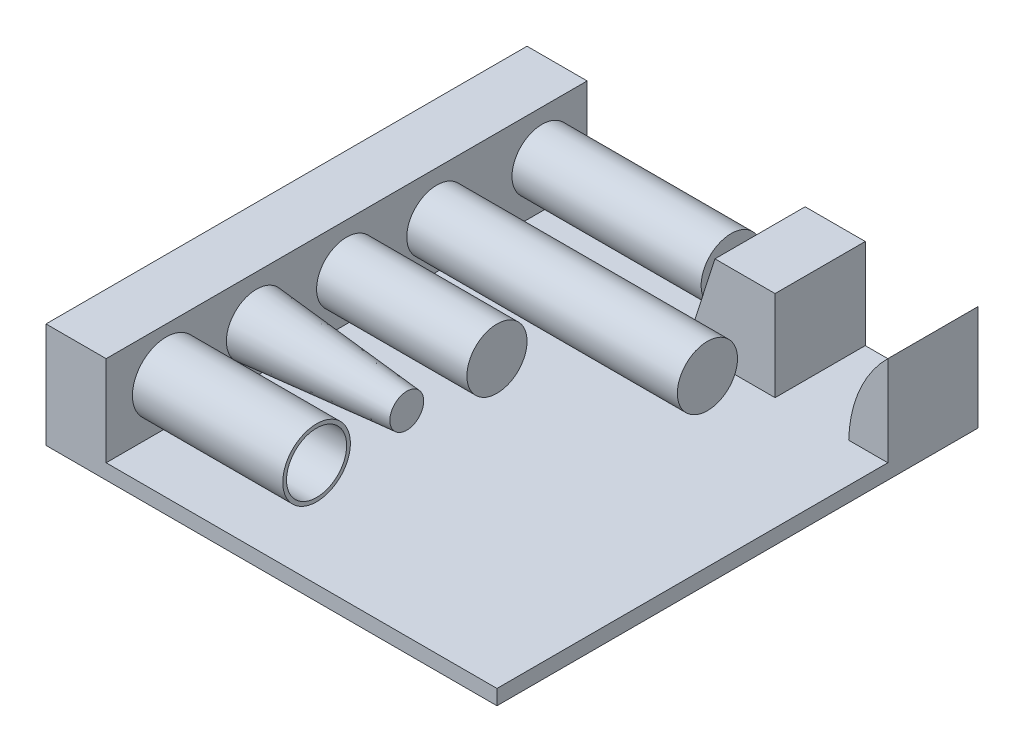
from build123d import *

# Parameters (mm, degrees)
BOSS_EXTRUDE1_DEPTH             = 640
BOSS_EXTRUDE2_DEPTH             = 120
ONE_SIDE_R                      = 40
BOSS_EXTRUDE3_DEPTH             = 251.6
BOTH_SIDES_R                    = 40
BOSS_EXTRUDE4_DEPTH             = 200
BOSS_EXTRUDE4_DIRECTION_2_REACH = 242
SOLID_2_R                       = 40
BOSS_EXTRUDE5_DEPTH             = 200
DRAFT_2_R                       = 40
BOSS_EXTRUDE6_DEPTH             = 200
BOSS_EXTRUDE6_TAPER             = 5
THICKEN_2_R                     = 45
THICKEN_2_R_2                   = 40
EXTRUDE_THIN1_DEPTH             = 200


with BuildPart() as part:
    # Sketch1 → Boss-Extrude1 (new body)
    with BuildSketch(Plane.XY):
        Polygon((-300, 0), (300, 0), (300, 20), (-220, 20), (-220, 140), (-300, 140), align=None)
    extrude(amount=BOSS_EXTRUDE1_DEPTH)

    # Sketch2 → Boss-Extrude2 (add)
    with BuildSketch(Plane.XY):
        with BuildLine():
            Line((300, 140), (300, 20))
            Line((300, 20), (247.956312481, 20))
            ThreePointArc((247.956312481, 20), (262.414199332, 85.015257999), (300, 140))
        make_face()
        Polygon((150, 140), (70, 140), (31.6, 20), (150, 20), align=None)
    extrude(amount=BOSS_EXTRUDE2_DEPTH)

    # One_Side → Boss-Extrude3 (add)
    with BuildSketch(Plane(origin=(-220, 0, 0), x_dir=(0, 0, -1), z_dir=(1, 0, 0))):
        with Locations((-60, 80)):
            Circle(ONE_SIDE_R)
    extrude(amount=BOSS_EXTRUDE3_DEPTH)

    # Both_Sides → Boss-Extrude4 (add)
    with BuildSketch(Plane(origin=(-60, 0, 0), x_dir=(0, 0, -1), z_dir=(1, 0, 0))):
        with Locations((-200, 80)):
            Circle(BOTH_SIDES_R)
    extrude(amount=BOSS_EXTRUDE4_DEPTH)

    # Both_Sides → Boss-Extrude4 direction 2 (add, up to next)
    with BuildSketch(Plane(origin=(-60, 0, 0), x_dir=(0, 0, -1), z_dir=(1, 0, 0)), mode=Mode.PRIVATE) as boss_extrude4_direction_2_sk1:
        with Locations((-200, 80)):
            Circle(BOTH_SIDES_R)
    boss_extrude4_direction_2_tool1 = extrude(boss_extrude4_direction_2_sk1.sketch, amount=-BOSS_EXTRUDE4_DIRECTION_2_REACH, mode=Mode.PRIVATE) - part.part
    add(boss_extrude4_direction_2_tool1.solids().sort_by_distance((-60, 80, 200))[0])

    # Solid 2 → Boss-Extrude5 (add)
    with BuildSketch(Plane(origin=(-220, 0, 0), x_dir=(0, 0, -1), z_dir=(1, 0, 0))):
        with Locations((-320, 80)):
            Circle(SOLID_2_R)
    extrude(amount=BOSS_EXTRUDE5_DEPTH)

    # Draft 2 → Boss-Extrude6 (add)
    with BuildSketch(Plane(origin=(-220, 0, 0), x_dir=(0, 0, -1), z_dir=(1, 0, 0))):
        with Locations((-440, 80)):
            Circle(DRAFT_2_R)
    extrude(amount=BOSS_EXTRUDE6_DEPTH, taper=BOSS_EXTRUDE6_TAPER)

    # Thicken 2 → Extrude-Thin1 (add)
    with BuildSketch(Plane(origin=(-220, 0, 0), x_dir=(0, 0, -1), z_dir=(1, 0, 0))):
        with Locations((-560, 80)):
            Circle(THICKEN_2_R)
        with Locations((-560, 80)):
            Circle(THICKEN_2_R_2, mode=Mode.SUBTRACT)
    extrude(amount=EXTRUDE_THIN1_DEPTH)


solid = part.part
